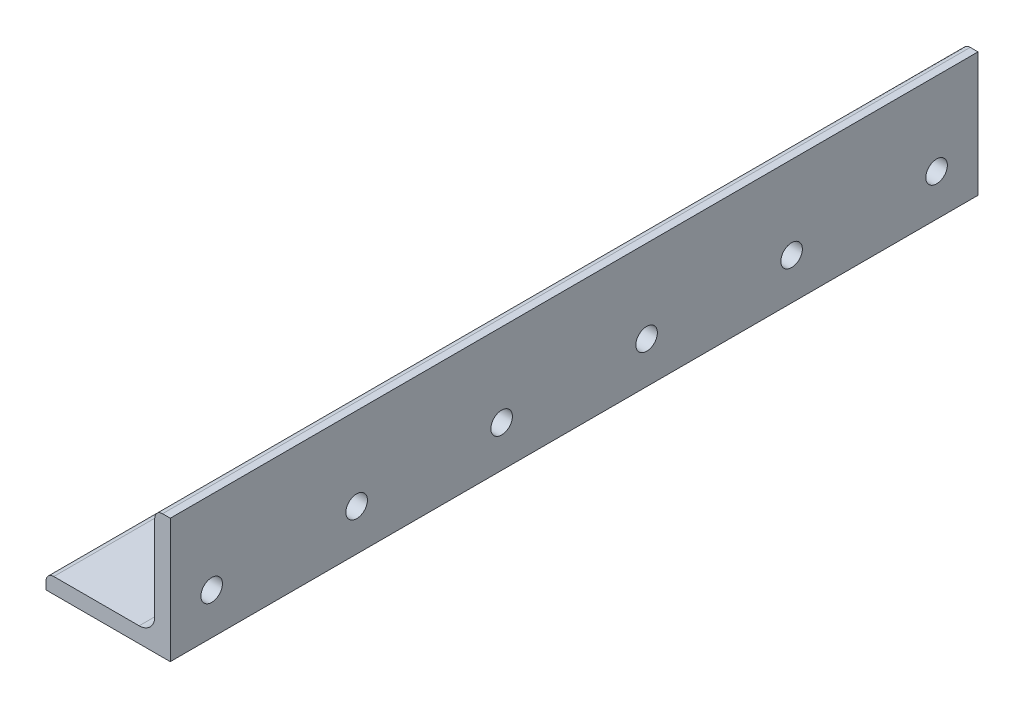
from build123d import *

# Parameters (mm, degrees)
BOSS_EXTRUDE1_DEPTH = 123.825
CUT_EXTRUDE1_REACH  = 40.1
SKETCH3_R           = 3.302
CUT_EXTRUDE2_REACH  = 40.1
SKETCH4_R           = 3.302


with BuildPart() as part:
    # Sketch2 → Boss-Extrude1 (new body, symmetric)
    with BuildSketch(Plane.XY):
        with BuildLine():
            Line((-19.05, -19.05), (19.05, -19.05))
            Line((19.05, -19.05), (19.05, 19.05))
            Line((19.05, 19.05), (16.66875, 19.05))
            ThreePointArc((16.66875, 19.05), (14.984951977, 18.352548023), (14.2875, 16.66875))
            Line((14.2875, 16.66875), (14.2875, -9.5123))
            ThreePointArc((14.2875, -9.5123), (12.888876302, -12.888876302), (9.5123, -14.2875))
            Line((9.5123, -14.2875), (-16.66875, -14.2875))
            ThreePointArc((-16.66875, -14.2875), (-18.352548023, -14.984951977), (-19.05, -16.66875))
            Line((-19.05, -16.66875), (-19.05, -19.05))
        make_face()
    extrude(amount=BOSS_EXTRUDE1_DEPTH, both=True)

    # Sketch3 → Cut-Extrude1 (cut, up to next)
    with BuildSketch(Plane(origin=(19.05, 0, 0), x_dir=(0, 0, -1), z_dir=(1, 0, 0)), mode=Mode.PRIVATE) as cut_extrude1_sk1:
        with Locations((111.125, -6.35)):
            Circle(SKETCH3_R)
    cut_extrude1_tool1 = extrude(cut_extrude1_sk1.sketch, amount=-CUT_EXTRUDE1_REACH, mode=Mode.PRIVATE) & part.part
    add(cut_extrude1_tool1.solids().sort_by_distance((19.05, -6.35, -111.125))[0], mode=Mode.SUBTRACT)
    # Sketch3 → Cut-Extrude1 (cut, up to next)
    with BuildSketch(Plane(origin=(19.05, 0, 0), x_dir=(0, 0, -1), z_dir=(1, 0, 0)), mode=Mode.PRIVATE) as cut_extrude1_sk2:
        with Locations((66.675, -6.35)):
            Circle(SKETCH3_R)
    cut_extrude1_tool2 = extrude(cut_extrude1_sk2.sketch, amount=-CUT_EXTRUDE1_REACH, mode=Mode.PRIVATE) & part.part
    add(cut_extrude1_tool2.solids().sort_by_distance((19.05, -6.35, -66.675))[0], mode=Mode.SUBTRACT)
    # Sketch3 → Cut-Extrude1 (cut, up to next)
    with BuildSketch(Plane(origin=(19.05, 0, 0), x_dir=(0, 0, -1), z_dir=(1, 0, 0)), mode=Mode.PRIVATE) as cut_extrude1_sk3:
        with Locations((22.225, -6.35)):
            Circle(SKETCH3_R)
    cut_extrude1_tool3 = extrude(cut_extrude1_sk3.sketch, amount=-CUT_EXTRUDE1_REACH, mode=Mode.PRIVATE) & part.part
    add(cut_extrude1_tool3.solids().sort_by_distance((19.05, -6.35, -22.225))[0], mode=Mode.SUBTRACT)
    # Sketch3 → Cut-Extrude1 (cut, up to next)
    with BuildSketch(Plane(origin=(19.05, 0, 0), x_dir=(0, 0, -1), z_dir=(1, 0, 0)), mode=Mode.PRIVATE) as cut_extrude1_sk4:
        with Locations((-22.225, -6.35)):
            Circle(SKETCH3_R)
    cut_extrude1_tool4 = extrude(cut_extrude1_sk4.sketch, amount=-CUT_EXTRUDE1_REACH, mode=Mode.PRIVATE) & part.part
    add(cut_extrude1_tool4.solids().sort_by_distance((19.05, -6.35, 22.225))[0], mode=Mode.SUBTRACT)
    # Sketch3 → Cut-Extrude1 (cut, up to next)
    with BuildSketch(Plane(origin=(19.05, 0, 0), x_dir=(0, 0, -1), z_dir=(1, 0, 0)), mode=Mode.PRIVATE) as cut_extrude1_sk5:
        with Locations((-66.675, -6.35)):
            Circle(SKETCH3_R)
    cut_extrude1_tool5 = extrude(cut_extrude1_sk5.sketch, amount=-CUT_EXTRUDE1_REACH, mode=Mode.PRIVATE) & part.part
    add(cut_extrude1_tool5.solids().sort_by_distance((19.05, -6.35, 66.675))[0], mode=Mode.SUBTRACT)
    # Sketch3 → Cut-Extrude1 (cut, up to next)
    with BuildSketch(Plane(origin=(19.05, 0, 0), x_dir=(0, 0, -1), z_dir=(1, 0, 0)), mode=Mode.PRIVATE) as cut_extrude1_sk6:
        with Locations((-111.125, -6.35)):
            Circle(SKETCH3_R)
    cut_extrude1_tool6 = extrude(cut_extrude1_sk6.sketch, amount=-CUT_EXTRUDE1_REACH, mode=Mode.PRIVATE) & part.part
    add(cut_extrude1_tool6.solids().sort_by_distance((19.05, -6.35, 111.125))[0], mode=Mode.SUBTRACT)

    # Sketch4 → Cut-Extrude2 (cut, up to next)
    with BuildSketch(Plane.XZ.offset(19.05), mode=Mode.PRIVATE) as cut_extrude2_sk1:
        with Locations((0, -92.075)):
            Circle(SKETCH4_R)
    cut_extrude2_tool1 = extrude(cut_extrude2_sk1.sketch, amount=-CUT_EXTRUDE2_REACH, mode=Mode.PRIVATE) & part.part
    add(cut_extrude2_tool1.solids().sort_by_distance((0, -19.05, -92.075))[0], mode=Mode.SUBTRACT)
    # Sketch4 → Cut-Extrude2 (cut, up to next)
    with BuildSketch(Plane.XZ.offset(19.05), mode=Mode.PRIVATE) as cut_extrude2_sk2:
        with Locations((0, -46.355)):
            Circle(SKETCH4_R)
    cut_extrude2_tool2 = extrude(cut_extrude2_sk2.sketch, amount=-CUT_EXTRUDE2_REACH, mode=Mode.PRIVATE) & part.part
    add(cut_extrude2_tool2.solids().sort_by_distance((0, -19.05, -46.355))[0], mode=Mode.SUBTRACT)
    # Sketch4 → Cut-Extrude2 (cut, up to next)
    with BuildSketch(Plane.XZ.offset(19.05), mode=Mode.PRIVATE) as cut_extrude2_sk3:
        with Locations((0, -0.635)):
            Circle(SKETCH4_R)
    cut_extrude2_tool3 = extrude(cut_extrude2_sk3.sketch, amount=-CUT_EXTRUDE2_REACH, mode=Mode.PRIVATE) & part.part
    add(cut_extrude2_tool3.solids().sort_by_distance((0, -19.05, -0.635))[0], mode=Mode.SUBTRACT)
    # Sketch4 → Cut-Extrude2 (cut, up to next)
    with BuildSketch(Plane.XZ.offset(19.05), mode=Mode.PRIVATE) as cut_extrude2_sk4:
        with Locations((0, 45.085)):
            Circle(SKETCH4_R)
    cut_extrude2_tool4 = extrude(cut_extrude2_sk4.sketch, amount=-CUT_EXTRUDE2_REACH, mode=Mode.PRIVATE) & part.part
    add(cut_extrude2_tool4.solids().sort_by_distance((0, -19.05, 45.085))[0], mode=Mode.SUBTRACT)
    # Sketch4 → Cut-Extrude2 (cut, up to next)
    with BuildSketch(Plane.XZ.offset(19.05), mode=Mode.PRIVATE) as cut_extrude2_sk5:
        with Locations((0, 90.805)):
            Circle(SKETCH4_R)
    cut_extrude2_tool5 = extrude(cut_extrude2_sk5.sketch, amount=-CUT_EXTRUDE2_REACH, mode=Mode.PRIVATE) & part.part
    add(cut_extrude2_tool5.solids().sort_by_distance((0, -19.05, 90.805))[0], mode=Mode.SUBTRACT)


solid = part.part
